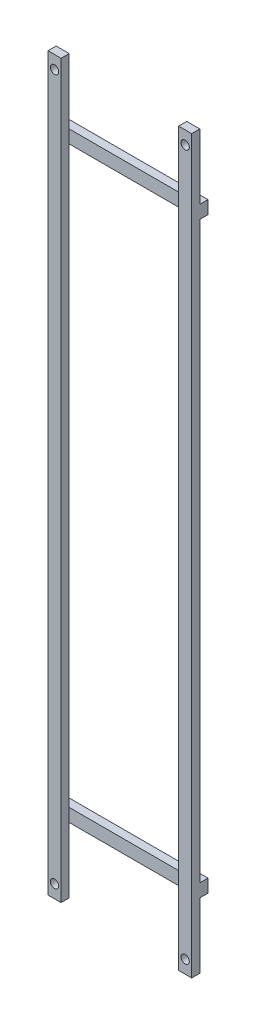
from build123d import *

# Parameters (mm, degrees)
SKETCH1_W            = 510
SKETCH1_H            = 80
BOSS_EXTRUDE1_DEPTH  = 10
SKETCH2_W            = 70
SKETCH2_H            = 390
CUT_EXTRUDE1_DEPTH   = 11
SKETCH3_W            = 70
SKETCH3_H            = 50
CUT_EXTRUDE2_DEPTH   = 11
SKETCH4_W            = 70
SKETCH4_H            = 10
BOSS_EXTRUDE2_DEPTH  = 100
SKETCH5_W            = 70
SKETCH5_H            = 50
CUT_EXTRUDE3_DEPTH   = 11
SKETCH6_W            = 70
SKETCH6_H            = 10
BOSS_EXTRUDE3_DEPTH  = 100
SKETCH7_W            = 10
SKETCH7_H            = 460
BOSS_EXTRUDE4_DEPTH  = 10
SKETCH8_W            = 10
SKETCH8_H            = 10
BOSS_EXTRUDE5_DEPTH  = 50
SKETCH9_W            = 90
SKETCH9_H            = 60
CUT_EXTRUDE4_DEPTH   = 61
SKETCH10_W           = 90
SKETCH10_H           = 60
CUT_EXTRUDE5_DEPTH   = 61
HOLE1_D              = 6.35
HOLE1_DEPTH          = 10
HOLE2_D              = 6.35
HOLE2_DEPTH          = 80
SCALE1_SCALE         = 4
SKETCH16_W           = 420.354500644
SKETCH16_H           = 2047.440969125
SKETCH16_W_2         = 504.269615058
SKETCH16_H_2         = 2143.883100275
CUT_EXTRUDE6_DEPTH   = 600
SKETCH17_W           = 706.747089412
SKETCH17_H           = 1090.886123918
CUT_EXTRUDE7_DEPTH   = 100
SKETCH18_W           = 40
SKETCH18_H           = 25
BOSS_EXTRUDE6_DEPTH  = 100
SKETCH20_W           = 40
SKETCH20_H           = 1120
SKETCH20_R           = 12.7
BOSS_EXTRUDE9_DEPTH  = 25
SKETCH21_W           = 440
SKETCH21_H           = 40
BOSS_EXTRUDE10_DEPTH = 25


with BuildPart() as part:
    # Sketch1 → Boss-Extrude1 (new body)
    with BuildSketch(Plane(origin=(45, 0, 0), x_dir=(0, -1, 0), z_dir=(-1, 0, 0))):
        with Locations((217.383525535, 40)):
            Rectangle(SKETCH1_W, SKETCH1_H)
    extrude(amount=-BOSS_EXTRUDE1_DEPTH)

    # Sketch2 → Cut-Extrude1 (cut, through all)
    with BuildSketch(Plane.ZY.offset(-45)):
        with Locations((35, -217.383525535)):
            Rectangle(SKETCH2_W, SKETCH2_H)
    extrude(amount=-CUT_EXTRUDE1_DEPTH, mode=Mode.SUBTRACT)

    # Sketch3 → Cut-Extrude2 (cut, through all)
    with BuildSketch(Plane.ZY.offset(-45)):
        with Locations((35, 12.616474465)):
            Rectangle(SKETCH3_W, SKETCH3_H)
    extrude(amount=-CUT_EXTRUDE2_DEPTH, mode=Mode.SUBTRACT)

    # Sketch4 → Boss-Extrude2 (add)
    with BuildSketch(Plane.ZY.offset(-45)):
        with Locations((35, -17.383525535)):
            Rectangle(SKETCH4_W, SKETCH4_H)
    extrude(amount=BOSS_EXTRUDE2_DEPTH)

    # Sketch5 → Cut-Extrude3 (cut, through all)
    with BuildSketch(Plane.ZY.offset(-45)):
        with Locations((35, -447.383525535)):
            Rectangle(SKETCH5_W, SKETCH5_H)
    extrude(amount=-CUT_EXTRUDE3_DEPTH, mode=Mode.SUBTRACT)

    # Sketch6 → Boss-Extrude3 (add)
    with BuildSketch(Plane.ZY.offset(-45)):
        with Locations((35, -417.383525535)):
            Rectangle(SKETCH6_W, SKETCH6_H)
    extrude(amount=BOSS_EXTRUDE3_DEPTH)

    # Sketch7 → Boss-Extrude4 (add)
    with BuildSketch(Plane.XY.offset(70)):
        with Locations((-50, -242.383525535)):
            Rectangle(SKETCH7_W, SKETCH7_H)
    extrude(amount=BOSS_EXTRUDE4_DEPTH)

    # Sketch8 → Boss-Extrude5 (add)
    with BuildSketch(Plane(origin=(0, -12.383525535, 0), x_dir=(-1, 0, 0), z_dir=(0, 1, 0))):
        with Locations((50, 75)):
            Rectangle(SKETCH8_W, SKETCH8_H)
    extrude(amount=BOSS_EXTRUDE5_DEPTH)

    # Sketch9 → Cut-Extrude4 (cut, through all)
    with BuildSketch(Plane.XZ.offset(22.383525535)):
        with Locations((0, 30)):
            Rectangle(SKETCH9_W, SKETCH9_H)
    extrude(amount=-CUT_EXTRUDE4_DEPTH, mode=Mode.SUBTRACT)

    # Sketch10 → Cut-Extrude5 (cut, through all)
    with BuildSketch(Plane(origin=(0, -412.383525535, 0), x_dir=(-1, 0, 0), z_dir=(0, 1, 0))):
        with Locations((0, 30)):
            Rectangle(SKETCH10_W, SKETCH10_H)
    extrude(amount=-CUT_EXTRUDE5_DEPTH, mode=Mode.SUBTRACT)

    # Hole1
    with Locations(Plane(origin=(0, 0, 70), x_dir=(-1, 0, 0), z_dir=(0, 0, -1))):
        with Locations((-50, 27.616474465), (50, -462.383525535)):
            Hole(HOLE1_D / 2, depth=HOLE1_DEPTH)

    # Hole2
    with Locations(Plane.XY.offset(80)):
        with Locations((50, -462.383525535), (-50, 27.616474465)):
            Hole(HOLE2_D / 2, depth=HOLE2_DEPTH)


with BuildPart() as part_1:
    # Scale1: scaled about (0, -217.383525535, 66.140384571)
    add(part.part.scale(SCALE1_SCALE).moved(Location((0, 652.150576605, -198.421153713))))

    # Sketch16 → Cut-Extrude6 (cut)
    with BuildSketch(Plane(origin=(220, 0, 0), x_dir=(0, 0, -1), z_dir=(1, 0, 0))):
        with Locations((153.598404035, -157.332882586)):
            Rectangle(SKETCH16_W, SKETCH16_H)
        with Locations((-358.713653816, -248.900281802)):
            Rectangle(SKETCH16_W_2, SKETCH16_H_2)
    extrude(amount=-CUT_EXTRUDE6_DEPTH, mode=Mode.SUBTRACT)

    # Sketch17 → Cut-Extrude7 (cut)
    with BuildSketch(Plane.XY.offset(106.578846287)):
        with Locations((133.373544706, 328.059536424)):
            Rectangle(SKETCH17_W, SKETCH17_H)
    extrude(amount=-CUT_EXTRUDE7_DEPTH, mode=Mode.SUBTRACT)

    # Sketch18 → Boss-Extrude6 (add)
    with BuildSketch(Plane(origin=(0, -217.383525535, 0), x_dir=(1, 0, 0), z_dir=(0, 1, 0))):
        with Locations((-200, -94.078846287)):
            Rectangle(SKETCH18_W, SKETCH18_H)
        with Locations((200, -94.078846287)):
            Rectangle(SKETCH18_W, SKETCH18_H)
    extrude(amount=BOSS_EXTRUDE6_DEPTH)

    # Sketch20 → Boss-Extrude9 (add)
    with BuildSketch(Plane.XY.offset(106.578846287)):
        with Locations((-200, 442.616474465)):
            Rectangle(SKETCH20_W, SKETCH20_H)
        with Locations((-200, 962.616474465)):
            Circle(SKETCH20_R, mode=Mode.SUBTRACT)
        with Locations((200, 442.616474465)):
            Rectangle(SKETCH20_W, SKETCH20_H)
        with Locations((200, 962.616474465)):
            Circle(SKETCH20_R, mode=Mode.SUBTRACT)
    extrude(amount=-BOSS_EXTRUDE9_DEPTH)

    # Sketch21 → Boss-Extrude10 (add)
    with BuildSketch(Plane(origin=(0, 0, 81.578846287), x_dir=(-1, 0, 0), z_dir=(0, 0, -1))):
        with Locations((0, 782.616474465)):
            Rectangle(SKETCH21_W, SKETCH21_H)
    extrude(amount=BOSS_EXTRUDE10_DEPTH)


solid = part_1.part
